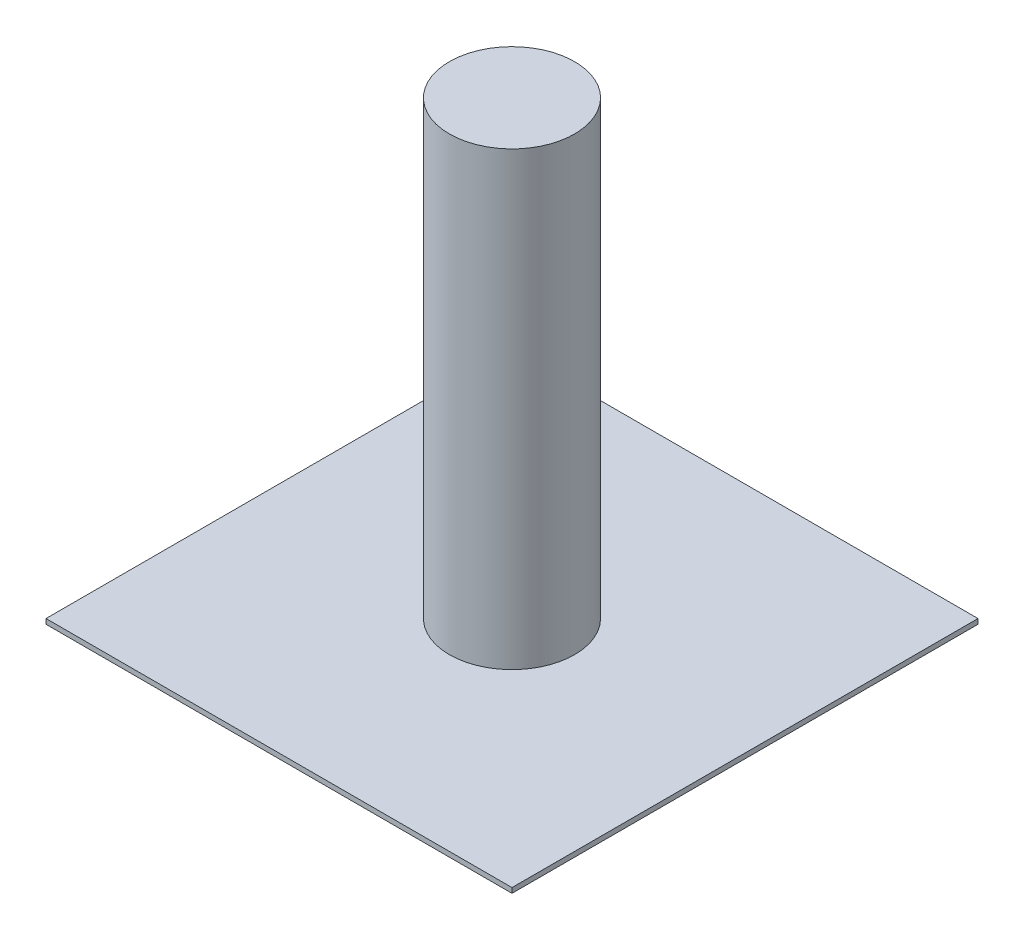
from build123d import *

# Parameters (mm, degrees)
SKETCH1_W           = 186
SKETCH1_H           = 186
BOSS_EXTRUDE1_DEPTH = 2
SKETCH2_R           = 25
BOSS_EXTRUDE2_DEPTH = 180


with BuildPart() as part:
    # Sketch1 → Boss-Extrude1 (new body)
    with BuildSketch(Plane(origin=(0, 0, 0), x_dir=(1, 0, 0), z_dir=(0, 1, 0))):
        Rectangle(SKETCH1_W, SKETCH1_H)
    extrude(amount=BOSS_EXTRUDE1_DEPTH)

    # Sketch2 → Boss-Extrude2 (add)
    with BuildSketch(Plane(origin=(0, 2, 0), x_dir=(1, 0, 0), z_dir=(0, 1, 0))):
        Circle(SKETCH2_R)
    extrude(amount=BOSS_EXTRUDE2_DEPTH)


solid = part.part
